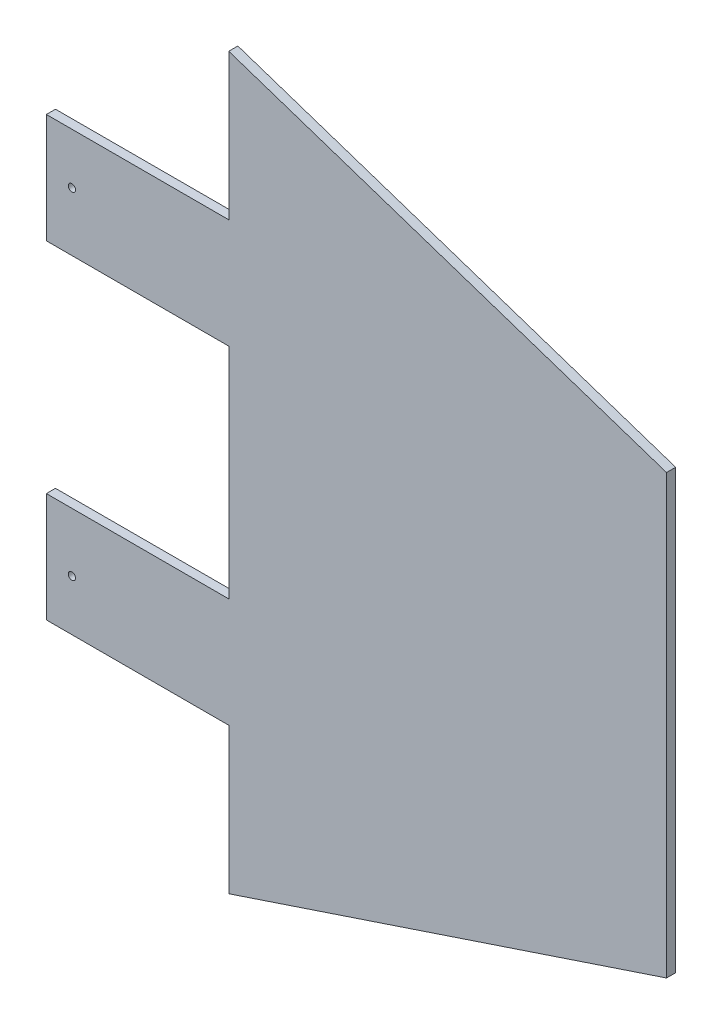
from build123d import *

# Parameters (mm, degrees)
BOSS_EXTRUDE1_DEPTH      = 1.5875
BOSS_EXTRUDE1_DEPTH_BACK = 1.5875
SKETCH2_R                = 1.26619
CUT_EXTRUDE1_DEPTH       = 279.333618388


with BuildPart() as part:
    # Sketch1 → Boss-Extrude1 (new, two sides: drawn at the far end of the back side and taken through both)
    with BuildSketch(Plane.XY.offset(-BOSS_EXTRUDE1_DEPTH_BACK)):
        Polygon((95.25, 127), (247.65, 76.2), (247.65, -76.2), (95.25, -127), (95.25, -76.2), (31.75, -76.2), (31.75, -38.1), (95.25, -38.1), (95.25, 38.1), (31.75, 38.1), (31.75, 76.2), (95.25, 76.2), align=None)
    extrude(amount=BOSS_EXTRUDE1_DEPTH + BOSS_EXTRUDE1_DEPTH_BACK)

    # Sketch2 → Cut-Extrude1 (cut, through all)
    with BuildSketch(Plane.XY.offset(1.5875)):
        with Locations((40.64, 58.512580329)):
            Circle(SKETCH2_R)
        with Locations((40.64, -58.512580329)):
            Circle(SKETCH2_R)
    extrude(amount=-CUT_EXTRUDE1_DEPTH, mode=Mode.SUBTRACT)


solid = part.part
